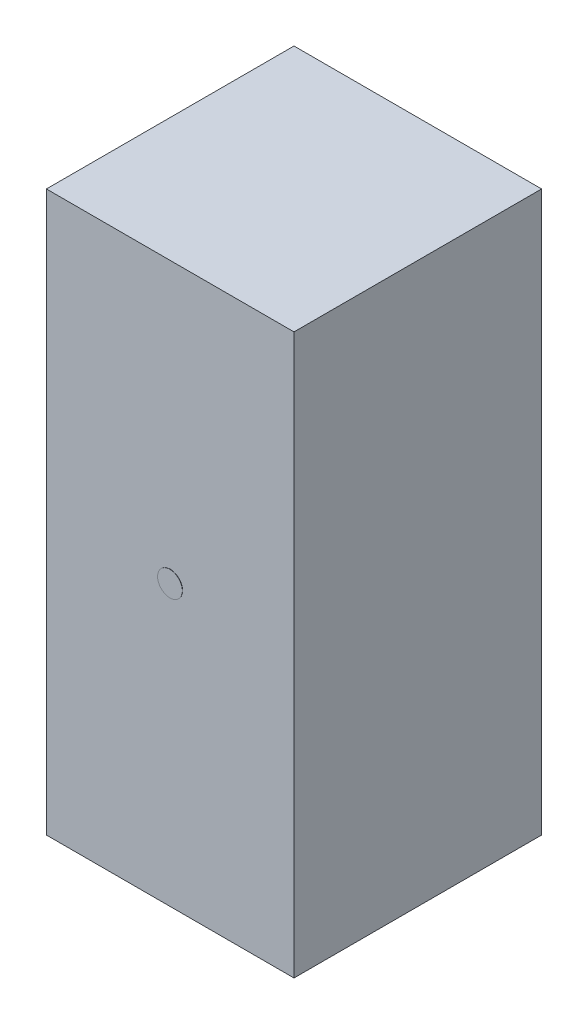
from build123d import *

# Parameters (mm, degrees)
SKETCH1_W           = 100
SKETCH1_H           = 100
BOSS_EXTRUDE1_DEPTH = 226
SKETCH2_R           = 5
BOSS_EXTRUDE2_DEPTH = 0.1


with BuildPart() as part:
    # Sketch1 → Boss-Extrude1 (new body)
    with BuildSketch(Plane(origin=(0, 0, 0), x_dir=(1, 0, 0), z_dir=(0, 1, 0))):
        Rectangle(SKETCH1_W, SKETCH1_H)
    extrude(amount=BOSS_EXTRUDE1_DEPTH)

    # Sketch2 → Boss-Extrude2 (add)
    with BuildSketch(Plane.XY.offset(50)):
        with Locations((0, 113)):
            Circle(SKETCH2_R)
    extrude(amount=BOSS_EXTRUDE2_DEPTH)


solid = part.part
